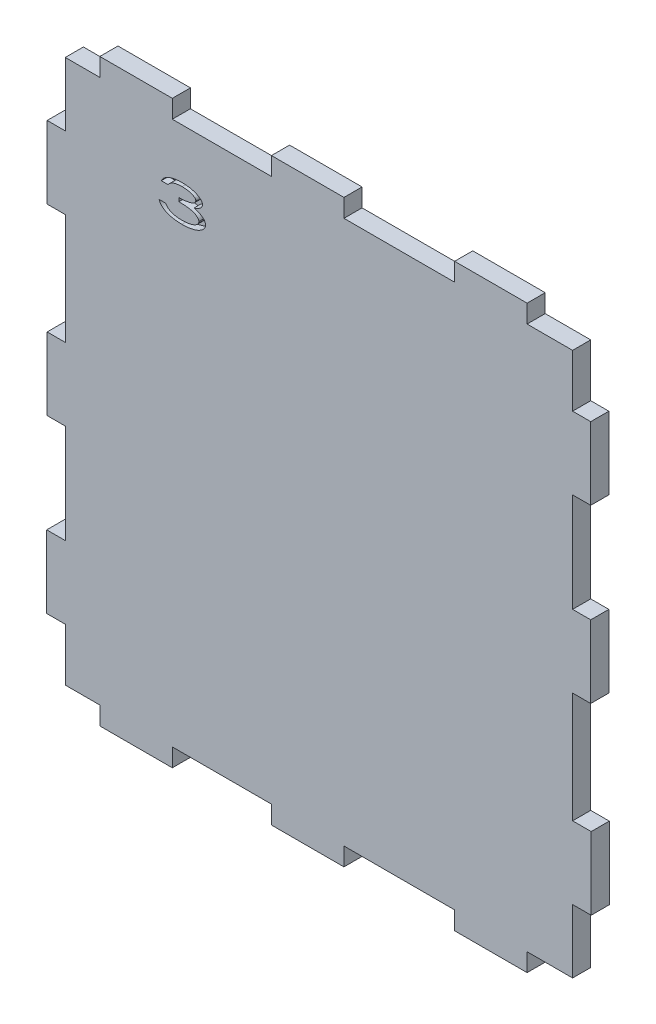
from build123d import *

# Parameters (mm, degrees)
BOSS_EXTRUDE1_DEPTH = 5
CUT_EXTRUDE1_DEPTH  = 2


with BuildPart() as part:
    # Sketch2 → Boss-Extrude1 (new body)
    with BuildSketch(Plane.XY):
        Polygon((-70, -75), (-60.46, -75), (-60.46, -80), (-40.46, -80), (-40.46, -75), (-13.1, -75), (-13.1, -80), (6.9, -80), (6.9, -75), (37.44, -75), (37.44, -80), (57.44, -80), (57.44, -75), (70, -75), (70, -57.44), (75.123655176, -57.44), (75.123655176, -37.44), (70, -37.44), (70, -6.9), (75, -6.9), (75, 13.1), (70, 13.1), (70, 40.46), (75, 40.46), (75, 60.46), (70, 60.46), (70, 75), (57.44, 75), (57.44, 80), (37.44, 80), (37.44, 75), (6.9, 75), (6.9, 80), (-13.1, 80), (-13.1, 75), (-40.46, 75), (-40.46, 80), (-60.46, 80), (-60.46, 75), (-70, 75), (-70, 57.44), (-75, 57.44), (-75, 37.44), (-70, 37.44), (-70, 6.9), (-75, 6.9), (-75, -13.1), (-70, -13.1), (-70, -40.46), (-75.123655176, -40.46), (-75.123655176, -60.46), (-70, -60.46), align=None)
    extrude(amount=BOSS_EXTRUDE1_DEPTH)

    # Sketch3 → Cut-Extrude1 (cut)
    with BuildSketch(Plane.XY.offset(5)):
        with BuildLine():
            Line((-41.678146167, 58.77788787), (-43.509876936, 58.77788787))
            add(Edge.make_bspline(
                [(-43.509876936, 58.77788787), (-43.461250169, 58.87460062), (-43.364067356, 59.067885465), (-43.1765855, 59.335956715), (-42.962814075, 59.589875354), (-42.714730978, 59.823661347), (-42.438273261, 60.043934871), (-42.127503625, 60.241827217), (-41.789160436, 60.429139537), (-41.418749578, 60.592184932), (-41.025998774, 60.740827628), (-40.612695419, 60.867995099), (-40.1827919, 60.976632395), (-39.735894594, 61.066646006), (-39.270842153, 61.134695385), (-38.788903582, 61.183530455), (-38.289240551, 61.215515003), (-37.950497105, 61.218616822), (-37.778086071, 61.220195563)],
                knots=[0, 0, 0, 0, 0.000324369, 0.000648266, 0.000978574, 0.001318668, 0.001669107, 0.00203746, 0.002422575, 0.002828255, 0.003250331, 0.003681842, 0.004124716, 0.004580118, 0.005048835, 0.005534115, 0.006033052, 0.006550222, 0.006550222, 0.006550222, 0.006550222], degree=3))
            add(Edge.make_bspline(
                [(-37.778086071, 61.220195563), (-37.527346675, 61.216482749), (-37.033905913, 61.209176146), (-36.306847346, 61.141966864), (-35.605759284, 61.036147882), (-35.040926616, 60.912523273), (-34.610478449, 60.792233532), (-34.306706327, 60.697780423), (-34.023095703, 60.591495642), (-33.755299239, 60.483241169), (-33.509242482, 60.361707209), (-33.280734293, 60.235889151), (-33.070417483, 60.102912436), (-32.880448311, 59.961830788), (-32.70943447, 59.817842928), (-32.563257659, 59.668049637), (-32.435008345, 59.5204344), (-32.333686501, 59.36767163), (-32.251730808, 59.215800935), (-32.196215754, 59.059990362), (-32.159852169, 58.903593821), (-32.155365904, 58.79779744), (-32.153146167, 58.745450971)],
                knots=[0, 0, 0, 0, 0.000752066, 0.001480022, 0.002188383, 0.002878172, 0.003212871, 0.003529079, 0.003832129, 0.004121273, 0.004395197, 0.004654839, 0.004903619, 0.005140985, 0.005364293, 0.005573423, 0.005768381, 0.005949896, 0.006122298, 0.006284662, 0.006444848, 0.006601726, 0.006601726, 0.006601726, 0.006601726], degree=3))
            add(Edge.make_bspline(
                [(-32.153146167, 58.745450971), (-32.155126096, 58.694461715), (-32.159063486, 58.59306185), (-32.186327754, 58.442882473), (-32.232483276, 58.297641284), (-32.296628003, 58.156182111), (-32.378640749, 58.019272628), (-32.479760829, 57.886257416), (-32.597672588, 57.757032565), (-32.734635531, 57.632268891), (-32.889703428, 57.512736416), (-33.062154603, 57.395708676), (-33.253316003, 57.284138037), (-33.46146636, 57.174369963), (-33.689530113, 57.073012353), (-33.933933045, 56.971074788), (-34.196654827, 56.873765887), (-34.379591801, 56.815658161), (-34.473338475, 56.785880659)],
                knots=[0, 0, 0, 0, 0.000152942, 0.000304148, 0.000456219, 0.000609078, 0.000769093, 0.000933949, 0.001109532, 0.001293201, 0.001488997, 0.001696449, 0.001917989, 0.002152687, 0.002402029, 0.002666369, 0.002947086, 0.003242144, 0.003242144, 0.003242144, 0.003242144], degree=3))
            add(Edge.make_bspline(
                [(-34.473338475, 56.785880659), (-34.371435391, 56.761651287), (-34.171953636, 56.714220754), (-33.880528366, 56.634623141), (-33.604053576, 56.544218933), (-33.340255139, 56.44836177), (-33.092410162, 56.340045514), (-32.856408634, 56.228340807), (-32.635078206, 56.106921494), (-32.49609775, 56.017114641), (-32.427905782, 55.97305013)],
                knots=[0, 0, 0, 0, 0.000314227, 0.000615119, 0.000905958, 0.001186675, 0.001456757, 0.001717051, 0.001969837, 0.002213352, 0.002213352, 0.002213352, 0.002213352], degree=3))
            add(Edge.make_bspline(
                [(-32.427905782, 55.97305013), (-32.338160668, 55.911190915), (-32.165189458, 55.791965894), (-31.936686888, 55.591523111), (-31.738360813, 55.390028215), (-31.579848645, 55.178657473), (-31.452574998, 54.963984376), (-31.36421615, 54.741246943), (-31.307833094, 54.513016508), (-31.301495408, 54.35788263), (-31.298338475, 54.280607221)],
                knots=[0, 0, 0, 0, 0.000326723, 0.000629713, 0.000910398, 0.001173329, 0.001420413, 0.001656742, 0.001890001, 0.002121513, 0.002121513, 0.002121513, 0.002121513], degree=3))
            add(Edge.make_bspline(
                [(-31.298338475, 54.280607221), (-31.300899497, 54.213617664), (-31.306042614, 54.079087309), (-31.348491278, 53.879113442), (-31.414621032, 53.680937358), (-31.513412096, 53.487611195), (-31.632714385, 53.293441858), (-31.783471455, 53.105438873), (-31.959101217, 52.918754973), (-32.15979884, 52.735433323), (-32.384776876, 52.558889526), (-32.629764698, 52.391130811), (-32.892602985, 52.231934866), (-33.177718676, 52.087875168), (-33.48005351, 51.949869865), (-33.803625176, 51.824971517), (-34.145663791, 51.707721075), (-34.507051222, 51.604063499), (-34.883389346, 51.511436281), (-35.271343575, 51.428709938), (-35.670461714, 51.360188127), (-36.080467574, 51.305586699), (-36.50104433, 51.261626563), (-36.932398229, 51.229039279), (-37.375303217, 51.209542088), (-37.674395565, 51.207677715), (-37.825787393, 51.206734024)],
                knots=[0, 0, 0, 0, 0.00020079, 0.000403233, 0.000610799, 0.000825834, 0.001052964, 0.001293447, 0.001547225, 0.001821381, 0.002108053, 0.002404435, 0.002711702, 0.003029151, 0.003362187, 0.003708366, 0.004069195, 0.004446608, 0.0048358, 0.005231729, 0.005636384, 0.006050331, 0.00647239, 0.006904828, 0.007347907, 0.00780206, 0.00780206, 0.00780206, 0.00780206], degree=3))
            add(Edge.make_bspline(
                [(-37.825787393, 51.206734024), (-38.028078024, 51.209066967), (-38.42402108, 51.21363323), (-39.005401639, 51.245401704), (-39.560431155, 51.302978851), (-40.090759702, 51.381182338), (-40.595641329, 51.478771562), (-41.074722886, 51.601241747), (-41.527932763, 51.746040276), (-41.954193829, 51.912599065), (-42.350193092, 52.100952867), (-42.712190164, 52.310428584), (-43.038672098, 52.541584475), (-43.327897722, 52.794420748), (-43.583397753, 53.06650901), (-43.798312003, 53.362695292), (-43.984424334, 53.676805501), (-44.074938178, 53.902097705), (-44.120453859, 54.01538787)],
                knots=[0, 0, 0, 0, 0.000606869, 0.001187823, 0.001746009, 0.002280298, 0.002795575, 0.003287971, 0.003762861, 0.004222064, 0.004659878, 0.005077132, 0.005475275, 0.005857957, 0.006227884, 0.006592342, 0.006953972, 0.007319761, 0.007319761, 0.007319761, 0.007319761], degree=3))
            Line((-44.120453859, 54.01538787), (-42.28872309, 54.01538787))
            add(Edge.make_bspline(
                [(-42.28872309, 54.01538787), (-42.245985894, 53.941529124), (-42.161425393, 53.795391027), (-42.015410404, 53.590286179), (-41.855237019, 53.401945268), (-41.682377998, 53.228180807), (-41.494745489, 53.0717692), (-41.293594062, 52.930451224), (-41.080008708, 52.802931853), (-40.928351486, 52.733703055), (-40.851959268, 52.69883138)],
                knots=[0, 0, 0, 0, 0.000255893, 0.000506313, 0.000754044, 0.0009969, 0.001240713, 0.001485814, 0.001733861, 0.001985623, 0.001985623, 0.001985623, 0.001985623], degree=3))
            add(Edge.make_bspline(
                [(-40.851959268, 52.69883138), (-40.749453073, 52.657301107), (-40.539329643, 52.57216983), (-40.206995706, 52.469900515), (-39.855455996, 52.378277332), (-39.482534853, 52.310587787), (-39.090193304, 52.251441535), (-38.676729761, 52.213436718), (-38.242721364, 52.187162362), (-37.946673475, 52.18484323), (-37.795258547, 52.183657101)],
                knots=[0, 0, 0, 0, 0.000331656, 0.000679848, 0.001042202, 0.001420911, 0.001816228, 0.00223221, 0.002666047, 0.003120228, 0.003120228, 0.003120228, 0.003120228], degree=3))
            add(Edge.make_bspline(
                [(-37.795258547, 52.183657101), (-37.624119432, 52.185320777), (-37.2898607, 52.188570169), (-36.801123171, 52.218747882), (-36.337815421, 52.261838168), (-35.901359211, 52.330270101), (-35.489744736, 52.412105719), (-35.104670295, 52.517826571), (-34.744421822, 52.638718129), (-34.413796228, 52.779403269), (-34.116322347, 52.932489462), (-33.855103936, 53.092031032), (-33.632936494, 53.258401976), (-33.449885693, 53.431155109), (-33.306548828, 53.612505965), (-33.206515059, 53.802083477), (-33.140142201, 53.997662583), (-33.133411239, 54.131907094), (-33.130069244, 54.198560947)],
                knots=[0, 0, 0, 0, 0.000513355, 0.001002654, 0.001468567, 0.001908699, 0.002327433, 0.002726891, 0.003105821, 0.003466599, 0.003803683, 0.004108685, 0.004383828, 0.004634837, 0.004861927, 0.00507361, 0.005275764, 0.005475117, 0.005475117, 0.005475117, 0.005475117], degree=3))
            add(Edge.make_bspline(
                [(-33.130069244, 54.198560947), (-33.131956638, 54.243214658), (-33.13574308, 54.332797765), (-33.165166562, 54.466276745), (-33.216534783, 54.596031609), (-33.282526991, 54.725698419), (-33.373402193, 54.849104845), (-33.477348732, 54.974680087), (-33.605217651, 55.094103952), (-33.749729059, 55.211374794), (-33.909429869, 55.326250016), (-34.084937972, 55.432002355), (-34.273161836, 55.53129438), (-34.47294817, 55.625651149), (-34.688013718, 55.708331501), (-34.914853672, 55.787187245), (-35.155663133, 55.857404311), (-35.412834886, 55.920975628), (-35.694007043, 55.979087806), (-36.007118868, 56.030477359), (-36.356828189, 56.072613863), (-36.741582609, 56.113121011), (-37.162132184, 56.146960684), (-37.618238404, 56.175269195), (-38.109943862, 56.198154055), (-38.449702535, 56.208248714), (-38.625261552, 56.213464793)],
                knots=[0, 0, 0, 0, 0.000133904, 0.000268635, 0.000407543, 0.000551775, 0.000703714, 0.000866179, 0.001040272, 0.001227417, 0.001424381, 0.001629885, 0.001841567, 0.002062654, 0.002292256, 0.002532413, 0.002782979, 0.003044445, 0.003326972, 0.003644105, 0.003996025, 0.004383529, 0.004804704, 0.005261626, 0.005754435, 0.006281338, 0.006281338, 0.006281338, 0.006281338], degree=3))
            Line((-38.625261552, 56.213464793), (-38.625261552, 57.19038787))
            add(Edge.make_bspline(
                [(-38.625261552, 57.19038787), (-38.40192866, 57.192399203), (-37.964983985, 57.196334322), (-37.325347864, 57.243237084), (-36.715423361, 57.308921487), (-36.229335297, 57.392276389), (-35.86303856, 57.472487726), (-35.609160547, 57.53244192), (-35.37614599, 57.599881752), (-35.160643019, 57.667059385), (-34.966748715, 57.742740115), (-34.789895081, 57.816848095), (-34.635109272, 57.900598515), (-34.496543261, 57.983873197), (-34.375328162, 58.071430769), (-34.272808138, 58.163791793), (-34.183485047, 58.254724131), (-34.111546902, 58.349546491), (-34.05638302, 58.446741831), (-34.015098132, 58.545782302), (-33.989023345, 58.646795137), (-33.98624687, 58.715411335), (-33.984876936, 58.749267077)],
                knots=[0, 0, 0, 0, 0.00066986, 0.001310562, 0.001923095, 0.002509687, 0.002788876, 0.003048034, 0.003292041, 0.003516511, 0.003724874, 0.003916289, 0.004091269, 0.004252271, 0.004401111, 0.004538967, 0.00466582, 0.004782975, 0.004894918, 0.005000155, 0.00510428, 0.005205694, 0.005205694, 0.005205694, 0.005205694], degree=3))
            add(Edge.make_bspline(
                [(-33.984876936, 58.749267077), (-33.988427727, 58.799242625), (-33.995611019, 58.900343749), (-34.047469355, 59.048267861), (-34.135872151, 59.187603999), (-34.252635715, 59.324420423), (-34.407200388, 59.451114112), (-34.591307614, 59.5758681), (-34.810051378, 59.692835765), (-35.059075618, 59.803902989), (-35.331942549, 59.907878069), (-35.626547884, 59.997818508), (-35.938317996, 60.072888328), (-36.26793162, 60.136795564), (-36.614628011, 60.183102537), (-36.979321543, 60.217590333), (-37.361248668, 60.238625303), (-37.622235426, 60.241704073), (-37.755189436, 60.243272486)],
                knots=[0, 0, 0, 0, 0.000149816, 0.000303079, 0.00046408, 0.000642685, 0.000840332, 0.001061542, 0.001309149, 0.001583285, 0.001879187, 0.002184583, 0.002506676, 0.002840847, 0.003191374, 0.003555527, 0.003939619, 0.004338476, 0.004338476, 0.004338476, 0.004338476], degree=3))
            add(Edge.make_bspline(
                [(-37.755189436, 60.243272486), (-37.863963512, 60.242027459), (-38.077802157, 60.239579864), (-38.392899762, 60.2246336), (-38.695806206, 60.197813734), (-38.987867325, 60.161159928), (-39.268907616, 60.116576558), (-39.538954985, 60.059284709), (-39.796544507, 59.990086194), (-40.044334123, 59.9125383), (-40.281423319, 59.82071634), (-40.508828188, 59.715417809), (-40.728134744, 59.597660104), (-40.935642459, 59.460576578), (-41.136339527, 59.312303087), (-41.327841025, 59.149422241), (-41.510114542, 58.971993436), (-41.621811145, 58.842964556), (-41.678146167, 58.77788787)],
                knots=[0, 0, 0, 0, 0.000326327, 0.000641526, 0.00094608, 0.001238361, 0.001524442, 0.001799499, 0.002066088, 0.00232436, 0.002578066, 0.002828203, 0.003075809, 0.003324017, 0.003573593, 0.003824014, 0.004077677, 0.004335801, 0.004335801, 0.004335801, 0.004335801], degree=3))
        make_face()
    extrude(amount=-CUT_EXTRUDE1_DEPTH, mode=Mode.SUBTRACT)


solid = part.part
